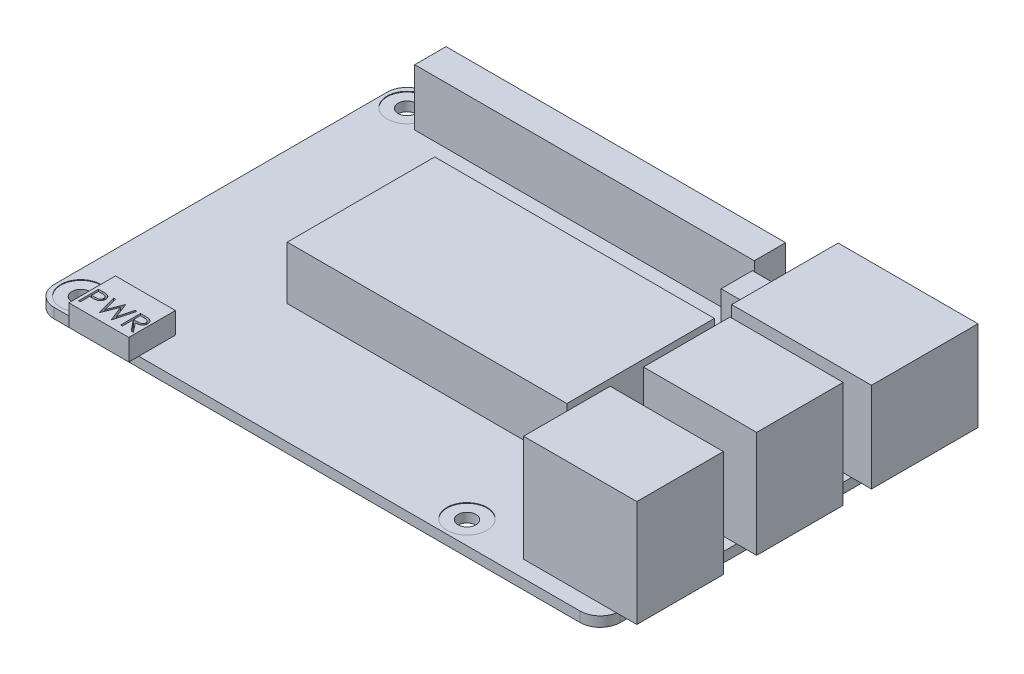
from build123d import *

# Parameters (mm, degrees)
SKETCH1_W           = 85
SKETCH1_H           = 56
SKETCH1_R           = 1.35
BOSS_EXTRUDE1_DEPTH = 1.5
FILLET1_R           = 3
SKETCH2_W           = 17
SKETCH2_H           = 13
BOSS_EXTRUDE2_DEPTH = 16
SKETCH3_W           = 21
SKETCH3_H           = 16
BOSS_EXTRUDE3_DEPTH = 13.5
SKETCH4_W           = 51
SKETCH4_H           = 4.7
SKETCH4_W_2         = 4.7
BOSS_EXTRUDE4_DEPTH = 8.5
SKETCH5_W           = 9
SKETCH5_H           = 7
BOSS_EXTRUDE5_DEPTH = 3.2
CUT_EXTRUDE1_DEPTH  = 1
SKETCH7_W           = 42
SKETCH7_H           = 22.15
BOSS_EXTRUDE6_DEPTH = 8
SKETCH9_R           = 3
CUT_EXTRUDE2_DEPTH  = 0.1


with BuildPart() as part:
    # Sketch1 → Boss-Extrude1 (new body)
    with BuildSketch(Plane(origin=(0, 0, 0), x_dir=(1, 0, 0), z_dir=(0, 1, 0))):
        with Locations((42.5, 28)):
            Rectangle(SKETCH1_W, SKETCH1_H)
        with Locations((3.5, 52.5)):
            Circle(SKETCH1_R, mode=Mode.SUBTRACT)
        with Locations((3.5, 3.5)):
            Circle(SKETCH1_R, mode=Mode.SUBTRACT)
        with Locations((61.5, 3.5)):
            Circle(SKETCH1_R, mode=Mode.SUBTRACT)
        with Locations((61.5, 52.5)):
            Circle(SKETCH1_R, mode=Mode.SUBTRACT)
    extrude(amount=BOSS_EXTRUDE1_DEPTH)

    # Fillet1
    fillet1_edges = [part.edges().sort_by_distance(p)[0] for p in [
        (0, 0.75, -56),
        (85, 0.75, -56),
        (85, 0.75, 0),
        (0, 0.75, 0),
    ]]
    fillet(fillet1_edges, radius=FILLET1_R)

    # Sketch2 → Boss-Extrude2 (add)
    with BuildSketch(Plane(origin=(0, 1.5, 0), x_dir=(1, 0, 0), z_dir=(0, 1, 0))):
        with Locations((79.5, 27)):
            Rectangle(SKETCH2_W, SKETCH2_H)
        with Locations((79.5, 9)):
            Rectangle(SKETCH2_W, SKETCH2_H)
    extrude(amount=BOSS_EXTRUDE2_DEPTH)

    # Sketch3 → Boss-Extrude3 (add)
    with BuildSketch(Plane(origin=(0, 1.5, 0), x_dir=(1, 0, 0), z_dir=(0, 1, 0))):
        with Locations((77.5, 45.75)):
            Rectangle(SKETCH3_W, SKETCH3_H)
    extrude(amount=BOSS_EXTRUDE3_DEPTH)

    # Sketch4 → Boss-Extrude4 (add)
    with BuildSketch(Plane(origin=(0, 1.5, 0), x_dir=(1, 0, 0), z_dir=(0, 1, 0))):
        with Locations((32.5, 52.5)):
            Rectangle(SKETCH4_W, SKETCH4_H)
        with Locations((61.5, 46.36)):
            Rectangle(SKETCH4_W_2, SKETCH4_H)
    extrude(amount=BOSS_EXTRUDE4_DEPTH)

    # Sketch5 → Boss-Extrude5 (add)
    with BuildSketch(Plane(origin=(0, 1.5, 0), x_dir=(1, 0, 0), z_dir=(0, 1, 0))):
        with Locations((11.2, 2)):
            Rectangle(SKETCH5_W, SKETCH5_H)
    extrude(amount=BOSS_EXTRUDE5_DEPTH)

    # Sketch6 → Cut-Extrude1 (cut)
    with BuildSketch(Plane(origin=(0, 4.7, 0), x_dir=(1, 0, 0), z_dir=(0, 1, 0))):
        with BuildLine():
            Line((7.161538462, 2.5), (7.749879808, 2.5))
            add(Edge.make_bspline(
                [(7.749879808, 2.5), (7.790346299, 2.499955518), (7.867881893, 2.499870287), (7.979066226, 2.497286219), (8.080045996, 2.493834769), (8.170603465, 2.489050289), (8.251017264, 2.483396069), (8.32092352, 2.475465749), (8.380871712, 2.467185496), (8.416791525, 2.458767148), (8.433173077, 2.454927885)],
                knots=[0, 0, 0, 0, 0.000121396, 0.0002326, 0.000333625, 0.000424498, 0.000504651, 0.000575397, 0.000635571, 0.000686023, 0.000686023, 0.000686023, 0.000686023], degree=3))
            add(Edge.make_bspline(
                [(8.433173077, 2.454927885), (8.453910392, 2.449251928), (8.494896372, 2.43803376), (8.553954409, 2.415564855), (8.610143419, 2.388922999), (8.663656184, 2.358559622), (8.713835112, 2.323171995), (8.761428862, 2.284194609), (8.806017416, 2.24072755), (8.847350038, 2.193258344), (8.885308436, 2.142583879), (8.917991021, 2.087947682), (8.945357215, 2.030269422), (8.968828591, 1.969589218), (8.985721552, 1.905397512), (8.998447466, 1.83814033), (9.006524861, 1.767824881), (9.007298485, 1.719773566), (9.007692308, 1.6953125)],
                knots=[0, 0, 0, 0, 6.4471e-05, 0.000127423, 0.000189252, 0.000250897, 0.000311748, 0.000373229, 0.000435277, 0.000498312, 0.000561894, 0.00062497, 0.000688943, 0.000753232, 0.000819855, 0.000887745, 0.00095849, 0.001031847, 0.001031847, 0.001031847, 0.001031847], degree=3))
            add(Edge.make_bspline(
                [(9.007692308, 1.6953125), (9.007331086, 1.670645834), (9.006624333, 1.622383837), (8.998141803, 1.551778589), (8.986715924, 1.484305684), (8.969147022, 1.420114726), (8.946136445, 1.359586923), (8.919143257, 1.301797295), (8.886585945, 1.247729005), (8.849176091, 1.197185762), (8.807560439, 1.150120122), (8.761915063, 1.106873156), (8.712424241, 1.067698009), (8.659245257, 1.032506857), (8.601859672, 1.00211576), (8.541137826, 0.974895213), (8.476551927, 0.952034304), (8.431858343, 0.940008537), (8.409134615, 0.933894231)],
                knots=[0, 0, 0, 0, 7.3957e-05, 0.000144703, 0.000213075, 0.000279118, 0.000343969, 0.000407141, 0.000470216, 0.000532959, 0.000595542, 0.000658457, 0.00072134, 0.000784678, 0.000849476, 0.000915925, 0.000984163, 0.001054742, 0.001054742, 0.001054742, 0.001054742], degree=3))
            add(Edge.make_bspline(
                [(8.409134615, 0.933894231), (8.390339758, 0.92989739), (8.349149734, 0.921138081), (8.281313115, 0.911359403), (8.202331356, 0.903012888), (8.112312259, 0.89675477), (8.011336626, 0.891397312), (7.899349834, 0.887138946), (7.776132054, 0.884799071), (7.690185273, 0.884678391), (7.6453125, 0.884615385)],
                knots=[0, 0, 0, 0, 5.7633e-05, 0.000126306, 0.00020548, 0.000295866, 0.000396973, 0.00050883, 0.000632051, 0.000766668, 0.000766668, 0.000766668, 0.000766668], degree=3))
            Line((7.6453125, 0.884615385), (7.430769231, 0.884615385))
            Line((7.430769231, 0.884615385), (7.430769231, -0.5))
            Line((7.430769231, -0.5), (7.161538462, -0.5))
            Line((7.161538462, -0.5), (7.161538462, 2.5))
        make_face()
        with BuildLine():
            Line((7.430769231, 2.192307692), (7.430769231, 1.192307692))
            Line((7.430769231, 1.192307692), (7.956009615, 1.185697115))
            add(Edge.make_bspline(
                [(7.956009615, 1.185697115), (7.981655266, 1.185683861), (8.031163666, 1.185658273), (8.102680429, 1.189074179), (8.169031246, 1.193017493), (8.230012311, 1.198791142), (8.285651112, 1.206952219), (8.336040423, 1.215190852), (8.380789522, 1.227109734), (8.433160267, 1.243158079), (8.491517422, 1.270528893), (8.555003892, 1.31025737), (8.608807251, 1.360897977), (8.655365791, 1.417836118), (8.692313687, 1.481178229), (8.71936168, 1.548951603), (8.735254101, 1.620461188), (8.737385124, 1.669393879), (8.738461538, 1.694110577)],
                knots=[0, 0, 0, 0, 7.6925e-05, 0.000148503, 0.000214742, 0.000276334, 0.000332172, 0.000383451, 0.000429365, 0.000470988, 0.000547631, 0.000621978, 0.000694704, 0.000768194, 0.000841992, 0.000913749, 0.000986363, 0.001060479, 0.001060479, 0.001060479, 0.001060479], degree=3))
            add(Edge.make_bspline(
                [(8.738461538, 1.694110577), (8.73737927, 1.718229303), (8.735227854, 1.766174345), (8.719237115, 1.836441854), (8.692366274, 1.903501029), (8.655117764, 1.966049388), (8.609911082, 2.022782648), (8.557368788, 2.0720659), (8.497614564, 2.111684502), (8.442030366, 2.137255887), (8.39265792, 2.15286898), (8.349773383, 2.163793129), (8.301352805, 2.172515077), (8.247380423, 2.179577508), (8.188274565, 2.185623332), (8.123527438, 2.189725598), (8.053384315, 2.192126846), (8.00468954, 2.192245951), (7.979447115, 2.192307692)],
                knots=[0, 0, 0, 0, 7.2318e-05, 0.000143759, 0.000214957, 0.000288238, 0.00036135, 0.000431937, 0.000503441, 0.000575509, 0.000614659, 0.000658677, 0.000708183, 0.000762152, 0.00082195, 0.000886391, 0.000956744, 0.001032468, 0.001032468, 0.001032468, 0.001032468], degree=3))
            Line((7.979447115, 2.192307692), (7.430769231, 2.192307692))
        make_face(mode=Mode.SUBTRACT)
        Polygon((9.430769231, 2.5), (9.709014423, 2.5), (10.296153846, 0.299879808), (11.169350962, 2.5), (11.208413462, 2.5), (12.065384615, 0.314903846), (12.655528846, 2.5), (12.930769231, 2.5), (12.121875, -0.5), (12.083413462, -0.5), (11.180769231, 1.794471154), (10.267307692, -0.5), (10.228846154, -0.5), align=None)
        with BuildLine():
            Line((13.469230769, 2.5), (14.069591346, 2.5))
            add(Edge.make_bspline(
                [(14.069591346, 2.5), (14.109655171, 2.499866641), (14.186582152, 2.499610576), (14.296787812, 2.498182779), (14.396925324, 2.494090474), (14.486942329, 2.490568831), (14.566837176, 2.484147167), (14.636854854, 2.47800947), (14.69667288, 2.469974903), (14.73288361, 2.462513112), (14.749278846, 2.459134615)],
                knots=[0, 0, 0, 0, 0.000120194, 0.000230785, 0.00033061, 0.000420853, 0.000501006, 0.00057103, 0.000631713, 0.000681921, 0.000681921, 0.000681921, 0.000681921], degree=3))
            add(Edge.make_bspline(
                [(14.749278846, 2.459134615), (14.771227381, 2.453711674), (14.814656229, 2.442981476), (14.877184857, 2.420301818), (14.936768564, 2.394056426), (14.993159842, 2.36323038), (15.046076234, 2.327594854), (15.096063358, 2.287765035), (15.14334804, 2.243958859), (15.186018009, 2.195071852), (15.226251482, 2.143783415), (15.26018459, 2.088323052), (15.289435859, 2.030327457), (15.312724873, 1.969206813), (15.331477422, 1.905553866), (15.344699913, 1.83879204), (15.352629502, 1.76922549), (15.353436807, 1.721775854), (15.353846154, 1.697716346)],
                knots=[0, 0, 0, 0, 6.7784e-05, 0.000134121, 0.000199228, 0.000262969, 0.00032664, 0.000390368, 0.000454569, 0.000519698, 0.000584846, 0.000649886, 0.000714388, 0.000779453, 0.000845823, 0.000913238, 0.000983386, 0.001055542, 0.001055542, 0.001055542, 0.001055542], degree=3))
            add(Edge.make_bspline(
                [(15.353846154, 1.697716346), (15.352587013, 1.657743399), (15.350130102, 1.579745827), (15.32722287, 1.466550786), (15.289700139, 1.360959945), (15.237994463, 1.263106255), (15.172149198, 1.17489713), (15.093013663, 1.097419597), (15.00054371, 1.032585386), (14.914461439, 0.98762584), (14.838420696, 0.958831918), (14.775820714, 0.938572182), (14.707534733, 0.922919069), (14.634217018, 0.908896098), (14.555562456, 0.898308932), (14.471759565, 0.890554708), (14.382748578, 0.885708381), (14.321600804, 0.884986662), (14.290144231, 0.884615385)],
                knots=[0, 0, 0, 0, 0.000119809, 0.000233778, 0.000344785, 0.000455008, 0.000564504, 0.000673722, 0.000785778, 0.000902162, 0.000963991, 0.001029562, 0.001099382, 0.001173991, 0.001253456, 0.001337355, 0.001426427, 0.001520795, 0.001520795, 0.001520795, 0.001520795], degree=3))
            Line((14.290144231, 0.884615385), (15.392307692, -0.5))
            Line((15.392307692, -0.5), (15.059375, -0.5))
            Line((15.059375, -0.5), (13.957211538, 0.884615385))
            Line((13.957211538, 0.884615385), (13.738461538, 0.884615385))
            Line((13.738461538, 0.884615385), (13.738461538, -0.5))
            Line((13.738461538, -0.5), (13.469230769, -0.5))
            Line((13.469230769, -0.5), (13.469230769, 2.5))
        make_face()
        with BuildLine():
            Line((13.738461538, 2.192307692), (13.738461538, 1.192307692))
            Line((13.738461538, 1.192307692), (14.287740385, 1.188100962))
            add(Edge.make_bspline(
                [(14.287740385, 1.188100962), (14.313386132, 1.188089616), (14.363094896, 1.188067625), (14.435009751, 1.191490861), (14.501969847, 1.195385134), (14.563719063, 1.201341716), (14.620284985, 1.209018349), (14.671639339, 1.218620907), (14.717865955, 1.229808389), (14.771778988, 1.247124068), (14.831981729, 1.274557798), (14.897408694, 1.314471083), (14.953124984, 1.364673185), (15.000197437, 1.422079005), (15.038022664, 1.485195789), (15.064690139, 1.553266963), (15.081612233, 1.624574047), (15.083608129, 1.673583854), (15.084615385, 1.698317308)],
                knots=[0, 0, 0, 0, 7.6925e-05, 0.000149103, 0.000215943, 0.000278133, 0.000335161, 0.00038714, 0.000434802, 0.000477752, 0.000556833, 0.000632702, 0.000706764, 0.000780634, 0.000854737, 0.000926494, 0.00099924, 0.001073356, 0.001073356, 0.001073356, 0.001073356], degree=3))
            add(Edge.make_bspline(
                [(15.084615385, 1.698317308), (15.083584995, 1.722442942), (15.081543139, 1.770251147), (15.064872766, 1.840241927), (15.036681868, 1.906299313), (14.998691378, 1.968154586), (14.952406388, 2.024302359), (14.898133977, 2.072342776), (14.837358096, 2.111985175), (14.780554211, 2.137317501), (14.729782029, 2.152848804), (14.685699464, 2.163778373), (14.635889625, 2.172559346), (14.580110661, 2.179594827), (14.518600692, 2.185641922), (14.451048705, 2.189714875), (14.377902893, 2.192126758), (14.327205524, 2.192245977), (14.300961538, 2.192307692)],
                knots=[0, 0, 0, 0, 7.2318e-05, 0.000143308, 0.000214407, 0.000286967, 0.000360372, 0.000431889, 0.000503565, 0.000577276, 0.000617571, 0.000662756, 0.000713443, 0.0007692, 0.00083139, 0.000898829, 0.000972186, 0.001050914, 0.001050914, 0.001050914, 0.001050914], degree=3))
            Line((14.300961538, 2.192307692), (13.738461538, 2.192307692))
        make_face(mode=Mode.SUBTRACT)
    extrude(amount=-CUT_EXTRUDE1_DEPTH, mode=Mode.SUBTRACT)

    # Sketch7 → Boss-Extrude6 (add)
    with BuildSketch(Plane(origin=(0, 1.5, 0), x_dir=(1, 0, 0), z_dir=(0, 1, 0))):
        with Locations((41, 29.075)):
            Rectangle(SKETCH7_W, SKETCH7_H)
    extrude(amount=BOSS_EXTRUDE6_DEPTH)

    # Sketch9 → Cut-Extrude2 (cut)
    with BuildSketch(Plane(origin=(0, 1.5, 0), x_dir=(1, 0, 0), z_dir=(0, 1, 0))):
        with Locations((3.5, 52.5)):
            Circle(SKETCH9_R)
        with Locations((3.5, 3.5)):
            Circle(SKETCH9_R)
        with Locations((61.5, 52.5)):
            Circle(SKETCH9_R)
        with Locations((61.5, 3.5)):
            Circle(SKETCH9_R)
    extrude(amount=-CUT_EXTRUDE2_DEPTH, mode=Mode.SUBTRACT)


solid = part.part
